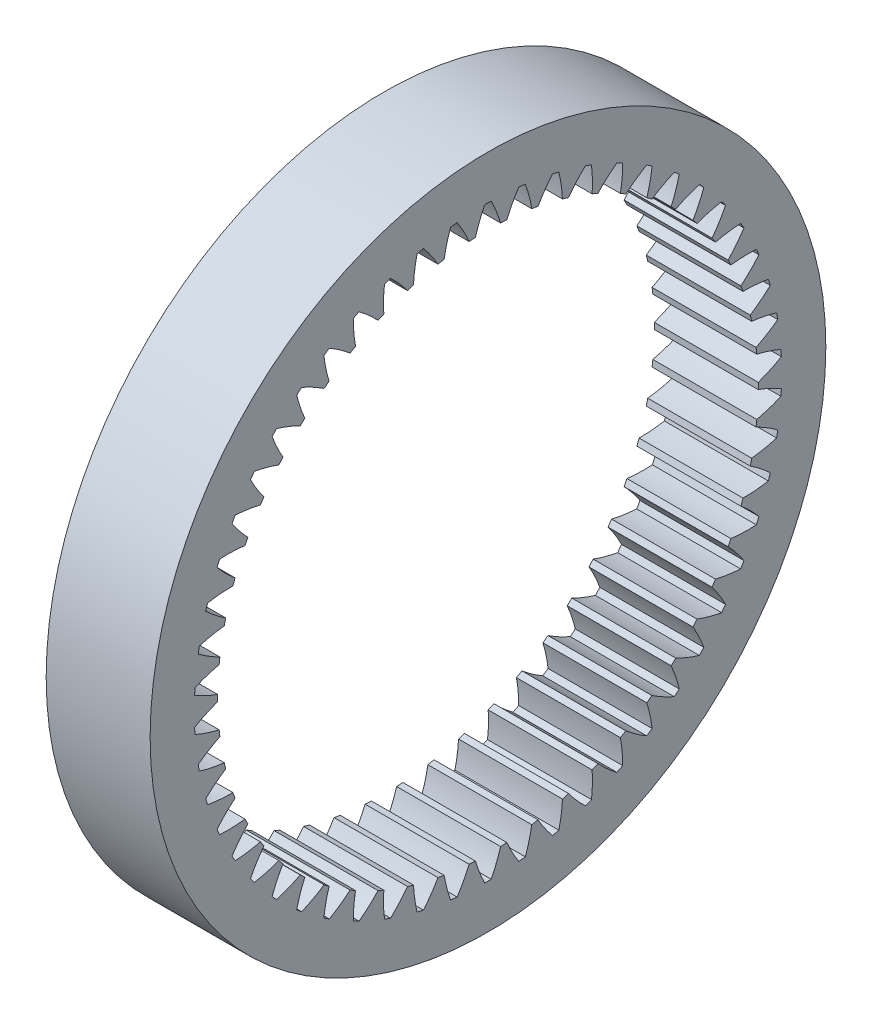
from build123d import *

# Parameters (mm, degrees)
BASPROSKE_W     = 20
BASPROSKE_H     = 13
TOOTHCUT_DEPTH  = 95.074438611
TEETHCUTS_COUNT = 54
TEETHCUTS_ANGLE = 353.333333333


with BuildPart() as part:
    # BasProSke → Base-Revolve (revolve)
    with BuildSketch(Plane(origin=(0, 0, 0), x_dir=(1, 0, 0), z_dir=(0, 1, 0))):
        with Locations((10, 58.5)):
            Rectangle(BASPROSKE_W, BASPROSKE_H)
    revolve(axis=Axis((-10, 0, 0), (1, 0, 0)))

    # TooCutSke → ToothCut (cut, through all)
    with BuildSketch(Plane(origin=(0, 0, 0), x_dir=(0, 0, -1), z_dir=(1, 0, 0))):
        with BuildLine():
            ThreePointArc((2.425973637, 51.917951588), (1.631114244, 54.248794358), (0.627188131, 56.497518849))
            ThreePointArc((0.627188131, 56.497518849), (0, 56.501), (-0.627188131, 56.497518849))
            ThreePointArc((-0.627188131, 56.497518849), (-1.631114244, 54.248794358), (-2.425973637, 51.917951588))
            ThreePointArc((-2.425973637, 51.917951588), (0, 51.9746), (2.425973637, 51.917951588))
        make_face()
    toothcut = extrude(amount=TOOTHCUT_DEPTH, mode=Mode.SUBTRACT)

    # TeethCuts: ToothCut ×54 about axis
    teethcuts_axis = Axis((-10, 0, 0), (1, 0, 0))
    for i in range(1, TEETHCUTS_COUNT):
        add(toothcut.rotate(teethcuts_axis, i * TEETHCUTS_ANGLE / (TEETHCUTS_COUNT - 1)), mode=Mode.SUBTRACT)


solid = part.part
